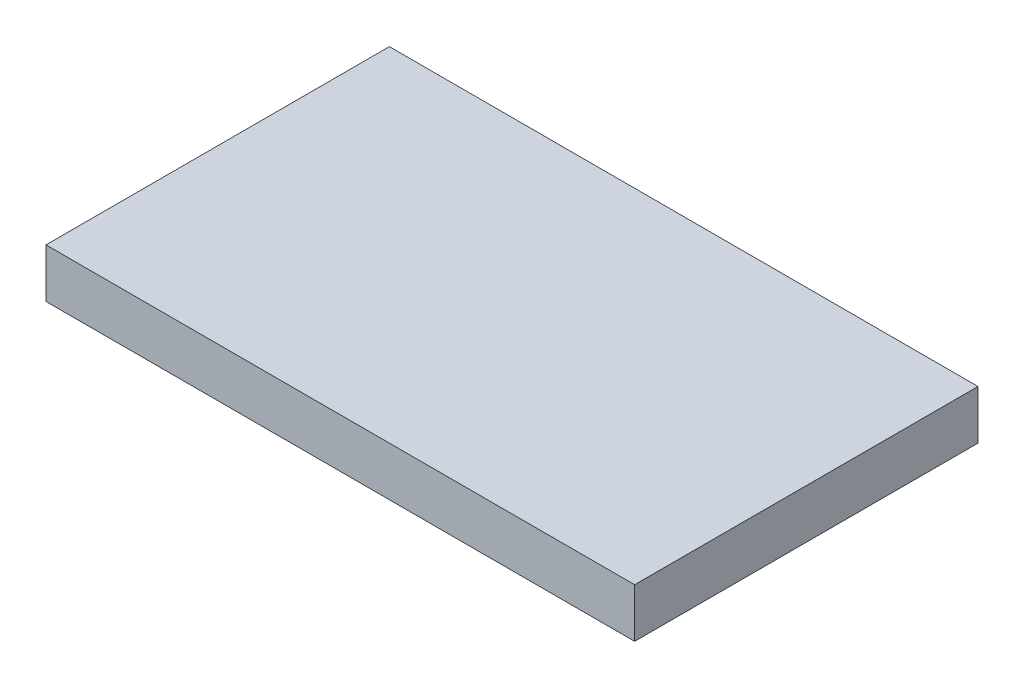
from build123d import *

# Parameters (mm, degrees)
SKETCH1_W           = 304.8
SKETCH1_H           = 177.8
BOSS_EXTRUDE1_DEPTH = 25.4


with BuildPart() as part:
    # Sketch1 → Boss-Extrude1 (new body)
    with BuildSketch(Plane(origin=(0, 0, 0), x_dir=(1, 0, 0), z_dir=(0, 1, 0))):
        with Locations((152.4, 88.9)):
            Rectangle(SKETCH1_W, SKETCH1_H)
    extrude(amount=BOSS_EXTRUDE1_DEPTH)


solid = part.part
